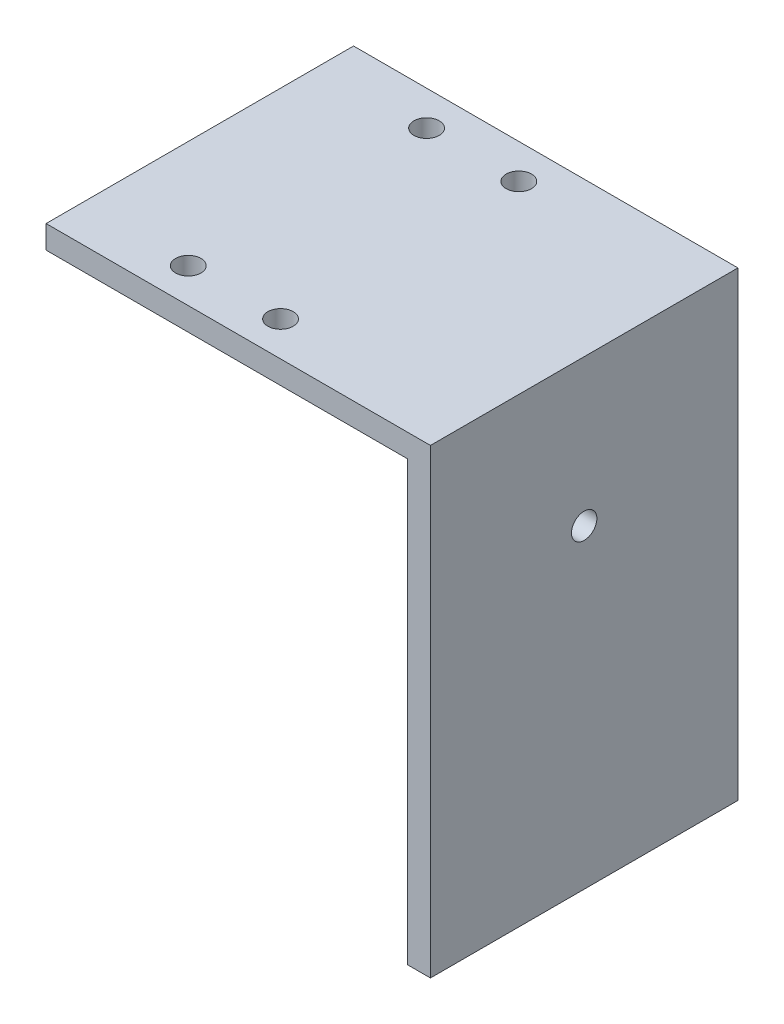
from build123d import *

# Parameters (mm, degrees)
EXTRUDE_1_DEPTH     = 40
SKETCH_2_R          = 1.65
CUT_EXTRUDE_1_DEPTH = 10
SKETCH_3_R          = 1.65
CUT_EXTRUDE_2_DEPTH = 10


with BuildPart() as part:
    # 草图1 → 凸台-拉伸1 (new body)
    with BuildSketch(Plane.XY):
        Polygon((0, 0), (50, 0), (50, -60), (47, -60), (47, -3), (0, -3), align=None)
    extrude(amount=EXTRUDE_1_DEPTH)

    # 草图2 → 切除-拉伸1 (cut)
    with BuildSketch(Plane(origin=(0, 0, 0), x_dir=(1, 0, 0), z_dir=(0, 1, 0))):
        with Locations((14, -4.5)):
            Circle(SKETCH_2_R)
        with Locations((14, -35.5)):
            Circle(SKETCH_2_R)
        with Locations((26, -4.5)):
            Circle(SKETCH_2_R)
        with Locations((26, -35.5)):
            Circle(SKETCH_2_R)
    extrude(amount=-CUT_EXTRUDE_1_DEPTH, mode=Mode.SUBTRACT)

    # 草图3 → 切除-拉伸2 (cut)
    with BuildSketch(Plane(origin=(50, 0, 0), x_dir=(0, 0, -1), z_dir=(1, 0, 0))):
        with Locations((-20, -19.05)):
            Circle(SKETCH_3_R)
    extrude(amount=-CUT_EXTRUDE_2_DEPTH, mode=Mode.SUBTRACT)


solid = part.part
